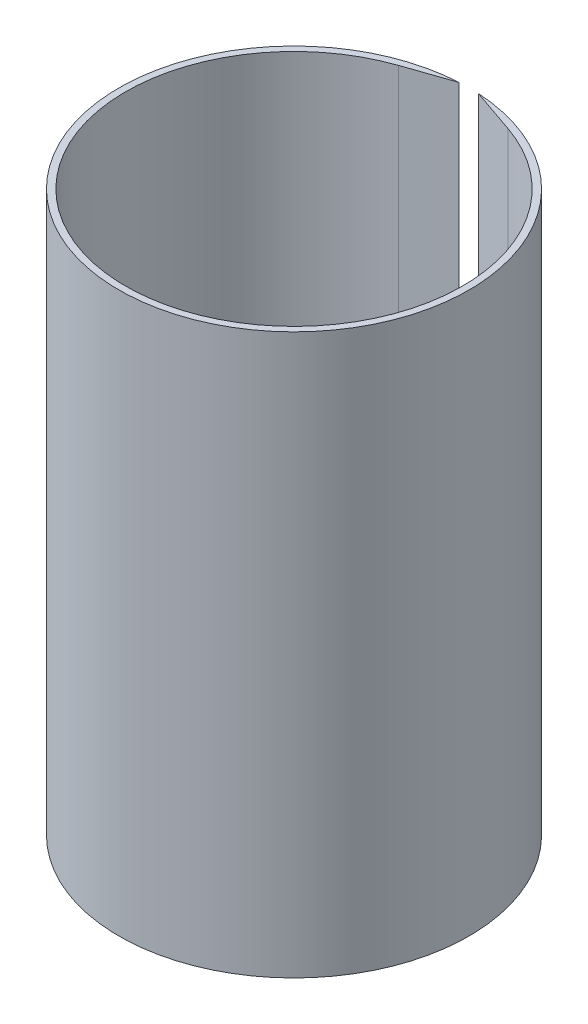
from build123d import *

# Parameters (mm, degrees)
BOSS_EXTRUDE1_DEPTH = 133.35


with BuildPart() as part:
    # Sketch1 → Boss-Extrude1 (new body)
    with BuildSketch(Plane(origin=(0, 0, 0), x_dir=(1, 0, 0), z_dir=(0, 1, 0))):
        with BuildLine():
            Line((-2.286, 41.656822782), (-13.064198444, 37.946068874))
            ThreePointArc((-13.064198444, 37.946068874), (0.021418672, -40.131994284), (13.02368695, 37.959992126))
            Line((13.02368695, 37.959992126), (2.286, 41.656822782))
            ThreePointArc((2.286, 41.656822782), (0, -41.7195), (-2.286, 41.656822782))
        make_face()
    extrude(amount=BOSS_EXTRUDE1_DEPTH)


solid = part.part
